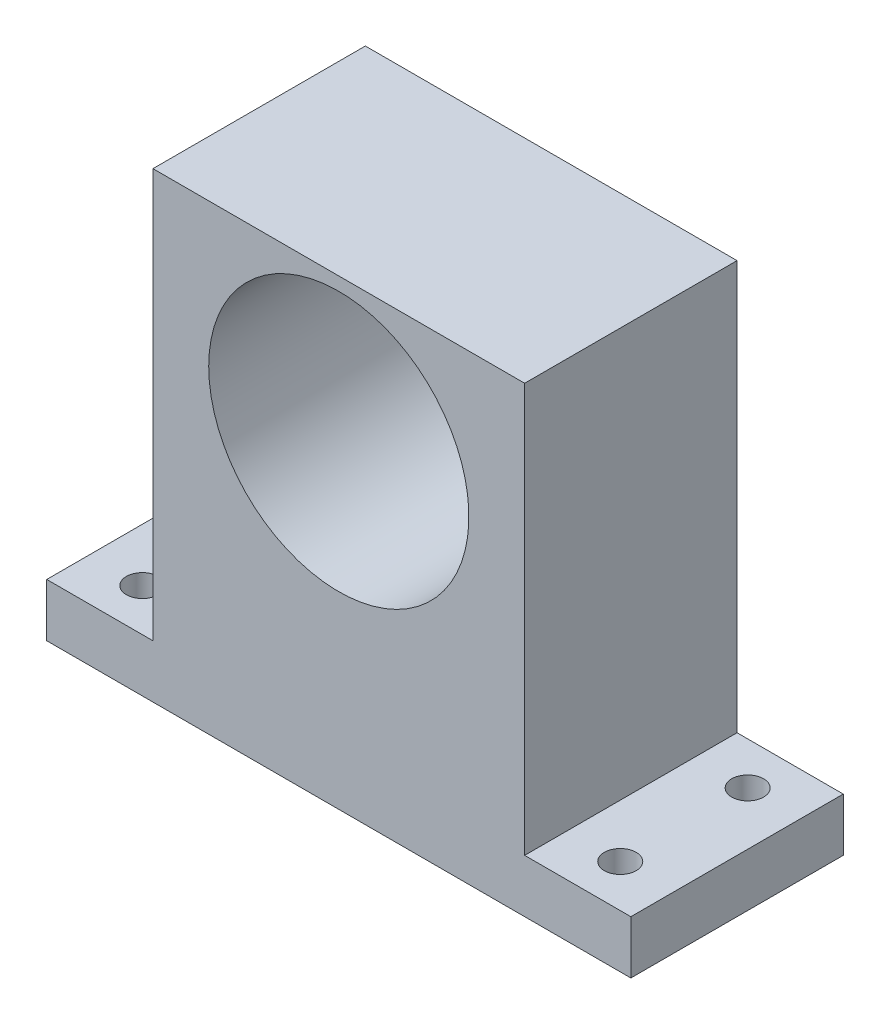
from build123d import *

# Parameters (mm, degrees)
SKETCH_1_W          = 35
SKETCH_1_H          = 43.5
EXTRUDE_1_DEPTH     = 20
SKETCH_2_W          = 20
SKETCH_2_H          = 5
EXTRUDE_2_DEPTH     = 10
SKETCH_3_W          = 20
SKETCH_3_H          = 5
EXTRUDE_3_DEPTH     = 10
SKETCH_4_R          = 1.5
CUT_EXTRUDE_2_DEPTH = 5
SKETCH_5_R          = 12.25
CUT_EXTRUDE_3_DEPTH = 20


with BuildPart() as part:
    # Эскиз1 → Бобышка-Вытянуть1 (new body)
    with BuildSketch(Plane.XY):
        Rectangle(SKETCH_1_W, SKETCH_1_H)
    extrude(amount=EXTRUDE_1_DEPTH)

    # Эскиз2 → Бобышка-Вытянуть2 (add)
    with BuildSketch(Plane(origin=(17.5, 0, 0), x_dir=(0, 0, -1), z_dir=(1, 0, 0))):
        with Locations((-10, -19.25)):
            Rectangle(SKETCH_2_W, SKETCH_2_H)
    extrude(amount=EXTRUDE_2_DEPTH)

    # Эскиз3 → Бобышка-Вытянуть3 (add)
    with BuildSketch(Plane.ZY.offset(17.5)):
        with Locations((10, -19.25)):
            Rectangle(SKETCH_3_W, SKETCH_3_H)
    extrude(amount=EXTRUDE_3_DEPTH)

    # Эскиз4 → Вырез-Вытянуть2 (cut)
    with BuildSketch(Plane(origin=(0, -16.75, 0), x_dir=(1, 0, 0), z_dir=(0, 1, 0))):
        with Locations((-22.5, -16)):
            Circle(SKETCH_4_R)
        with Locations((-22.5, -4)):
            Circle(SKETCH_4_R)
        with Locations((22.5, -16)):
            Circle(SKETCH_4_R)
        with Locations((22.5, -4)):
            Circle(SKETCH_4_R)
    extrude(amount=-CUT_EXTRUDE_2_DEPTH, mode=Mode.SUBTRACT)

    # Эскиз5 → Вырез-Вытянуть3 (cut)
    with BuildSketch(Plane(origin=(0, 0, 0), x_dir=(-1, 0, 0), z_dir=(0, 0, -1))):
        with Locations((0, 8.25)):
            Circle(SKETCH_5_R)
    extrude(amount=-CUT_EXTRUDE_3_DEPTH, mode=Mode.SUBTRACT)


solid = part.part
